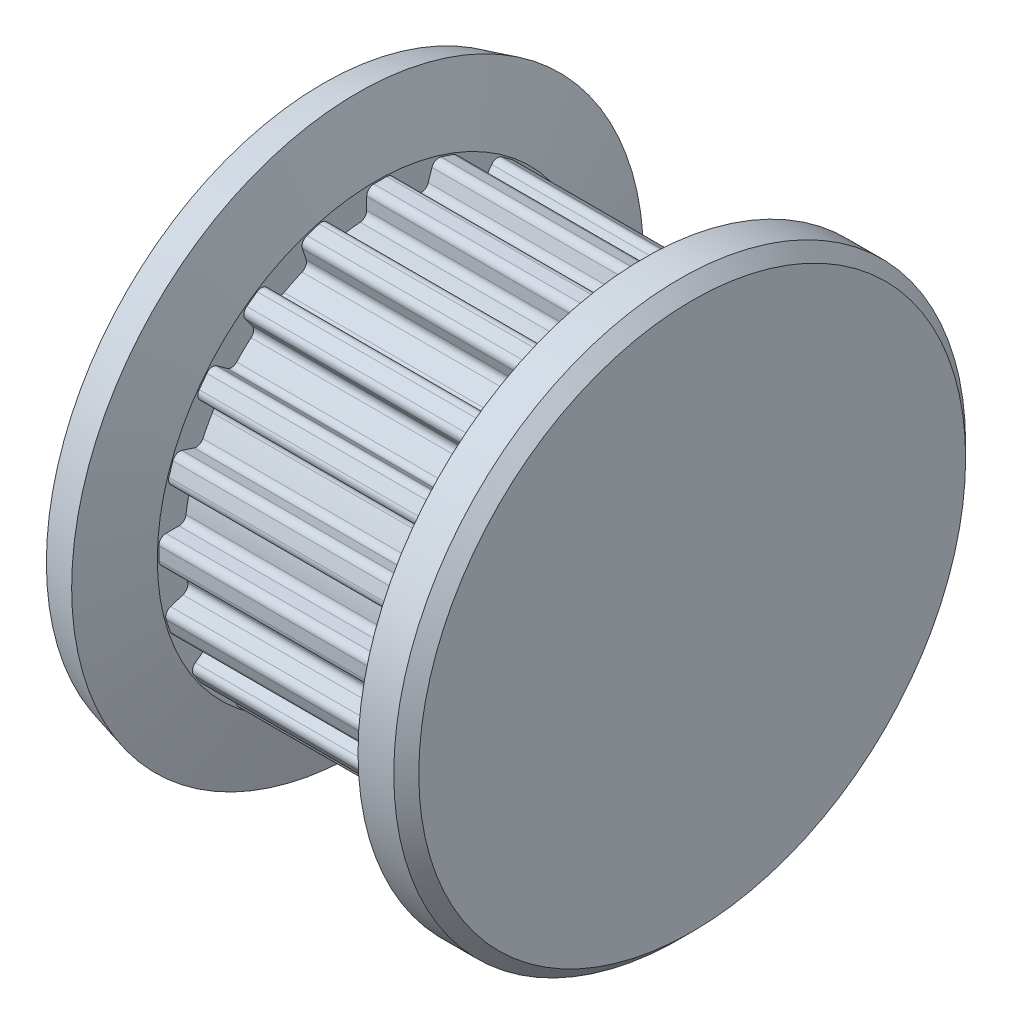
from build123d import *

# Parameters (mm, degrees)
SKETCH2_W                = 0.76
SKETCH2_H                = 0.76
BOSS_EXTRUDE1_DEPTH      = 7
FILLET1_R                = 0.2
CIRPATTERN2_COUNT        = 20
FILLET1_OF_CIRPATTERN2_R = 0.2
SKETCH4_R                = 2.85
BOSS_EXTRUDE2_DEPTH      = 9.856424


with BuildPart() as part:
    # Sketch1 → Revolve2 (revolve)
    with BuildSketch(Plane.XY):
        Polygon((2.078789587, 5.5), (1.078789587, 5.5), (0.572365613, 3.61), (0.572365613, 2.85), (-6.427634387, 2.85), (-6.427634387, 3.61), (-6.934058361, 5.5), (-7.899984187, 5.241180955), (-7.427634387, 3.478347502), (-7.427634387, 2.85), (-7.427634387, 0.35), (-7.077634387, 0), (2.078789587, 0), (2.428789587, 0.35), (2.428789587, 5.15), align=None)
    revolve(axis=Axis((-7.427634387, -2.5, 0), (1, 0, 0)))

    # Sketch2 → Boss-Extrude1 (add)
    with BuildSketch(Plane.ZY.offset(-0.572365613)):
        with Locations((-0.13, 3.186628075)):
            Rectangle(SKETCH2_W, SKETCH2_H)
    boss_extrude1 = extrude(amount=BOSS_EXTRUDE1_DEPTH)

    # Fillet1
    fillet1_edges = [part.edges().sort_by_distance(p)[0] for p in [
        (-2.927634387, 2.825636112, -0.51),
        (-2.927634387, 3.566628075, -0.51),
        (-2.927634387, 2.844155686, 0.25),
        (-2.927634387, 3.566628075, 0.25),
    ]]
    fillet(fillet1_edges, radius=FILLET1_R)

    # CirPattern2: Boss-Extrude1 ×20 about axis
    cirpattern2_axis = Axis((0, -2.5, 0), (1, 0, 0))
    for i in range(1, CIRPATTERN2_COUNT):
        add(boss_extrude1.rotate(cirpattern2_axis, i * 360 / CIRPATTERN2_COUNT))

    # Fillet1 of CirPattern2
    fillet1_of_cirpattern2_edges = [part.edges().sort_by_distance(p)[0] for p in [
        (-2.927634387, 2.722579595, 1.160673241),
        (-2.927634387, 3.42730483, 1.38965235),
        (-2.927634387, 2.505339841, 1.889199057),
        (-2.927634387, 3.192451914, 2.112455303),
        (-2.927634387, 2.108300599, 2.717731699),
        (-2.927634387, 2.70777569, 3.153275847),
        (-2.927634387, 1.676566458, 3.343470147),
        (-2.927634387, 2.261058898, 3.768128762),
        (-2.927634387, 1.042929033, 4.008759642),
        (-2.927634387, 1.478473181, 4.608234733),
        (-2.927634387, 0.43896165, 4.470459084),
        (-2.927634387, 0.863620265, 5.054951524),
        (-2.927634387, -0.369249112, 4.907382261),
        (-2.927634387, -0.140270003, 5.612107496),
        (-2.927634387, -1.086329201, 5.159848338),
        (-2.927634387, -0.863072955, 5.846960411),
        (-2.927634387, -1.99, 5.325636112),
        (-2.927634387, -1.99, 6.066628075),
        (-2.927634387, -2.75, 5.344155686),
        (-2.927634387, -2.75, 6.066628075),
        (-2.927634387, -3.660673241, 5.222579595),
        (-2.927634387, -3.88965235, 5.92730483),
        (-2.927634387, -4.389199057, 5.005339841),
        (-2.927634387, -4.612455303, 5.692451914),
        (-2.927634387, -5.217731699, 4.608300599),
        (-2.927634387, -5.653275847, 5.20777569),
        (-2.927634387, -5.843470147, 4.176566458),
        (-2.927634387, -6.268128762, 4.761058898),
        (-2.927634387, -6.508759642, 3.542929033),
        (-2.927634387, -7.108234733, 3.978473181),
        (-2.927634387, -6.970459084, 2.93896165),
        (-2.927634387, -7.554951524, 3.363620265),
        (-2.927634387, -7.407382261, 2.130750888),
        (-2.927634387, -8.112107496, 2.359729997),
        (-2.927634387, -7.659848338, 1.413670799),
        (-2.927634387, -8.346960411, 1.636927045),
        (-2.927634387, -7.825636112, 0.51),
        (-2.927634387, -8.566628075, 0.51),
        (-2.927634387, -7.844155686, -0.25),
        (-2.927634387, -8.566628075, -0.25),
        (-2.927634387, -7.722579595, -1.160673241),
        (-2.927634387, -8.42730483, -1.38965235),
        (-2.927634387, -7.505339841, -1.889199057),
        (-2.927634387, -8.192451914, -2.112455303),
        (-2.927634387, -7.108300599, -2.717731699),
        (-2.927634387, -7.70777569, -3.153275847),
        (-2.927634387, -6.676566458, -3.343470147),
        (-2.927634387, -7.261058898, -3.768128762),
        (-2.927634387, -6.042929033, -4.008759642),
        (-2.927634387, -6.478473181, -4.608234733),
        (-2.927634387, -5.43896165, -4.470459084),
        (-2.927634387, -5.863620265, -5.054951524),
        (-2.927634387, -4.630750888, -4.907382261),
        (-2.927634387, -4.859729997, -5.612107496),
        (-2.927634387, -3.913670799, -5.159848338),
        (-2.927634387, -4.136927045, -5.846960411),
        (-2.927634387, -3.01, -5.325636112),
        (-2.927634387, -3.01, -6.066628075),
        (-2.927634387, -2.25, -5.344155686),
        (-2.927634387, -2.25, -6.066628075),
        (-2.927634387, -1.339326759, -5.222579595),
        (-2.927634387, -1.11034765, -5.92730483),
        (-2.927634387, -0.610800943, -5.005339841),
        (-2.927634387, -0.387544697, -5.692451914),
        (-2.927634387, 0.217731699, -4.608300599),
        (-2.927634387, 0.653275847, -5.20777569),
        (-2.927634387, 0.843470147, -4.176566458),
        (-2.927634387, 1.268128762, -4.761058898),
        (-2.927634387, 1.508759642, -3.542929033),
        (-2.927634387, 2.108234733, -3.978473181),
        (-2.927634387, 1.970459084, -2.93896165),
        (-2.927634387, 2.554951524, -3.363620265),
        (-2.927634387, 2.407382261, -2.130750888),
        (-2.927634387, 3.112107496, -2.359729997),
        (-2.927634387, 2.659848338, -1.413670799),
        (-2.927634387, 3.346960411, -1.636927045),
    ]]
    fillet(fillet1_of_cirpattern2_edges, radius=FILLET1_OF_CIRPATTERN2_R)

    # Sketch4 → Boss-Extrude2 (add)
    with BuildSketch(Plane(origin=(2.428789587, 0, 0), x_dir=(0, 0, -1), z_dir=(1, 0, 0))):
        with Locations((0, -2.5)):
            Circle(SKETCH4_R)
    extrude(amount=-BOSS_EXTRUDE2_DEPTH)


solid = part.part
